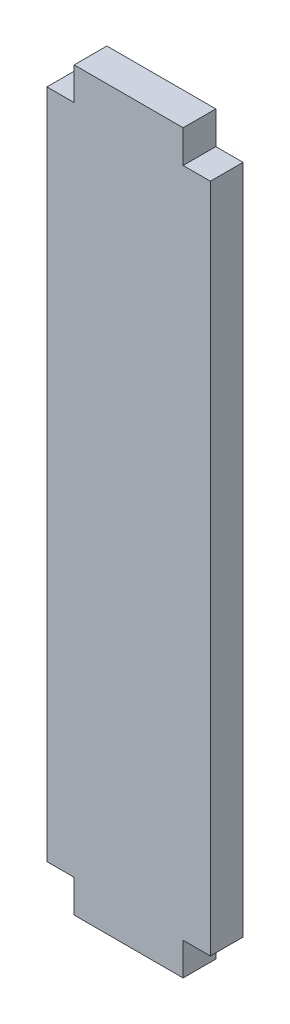
from build123d import *

# Parameters (mm, degrees)
SKETCH1_W           = 2.5
SKETCH1_H           = 61.6
SKETCH1_W_2         = 10
SKETCH1_H_2         = 67.6
BOSS_EXTRUDE1_DEPTH = 3


with BuildPart() as part:
    # Sketch1 → Boss-Extrude1 (new body)
    with BuildSketch(Plane.XY):
        with Locations((-6.25, 0)):
            Rectangle(SKETCH1_W, SKETCH1_H)
        Rectangle(SKETCH1_W_2, SKETCH1_H_2)
        with Locations((6.25, 0)):
            Rectangle(SKETCH1_W, SKETCH1_H)
    extrude(amount=BOSS_EXTRUDE1_DEPTH)


solid = part.part
